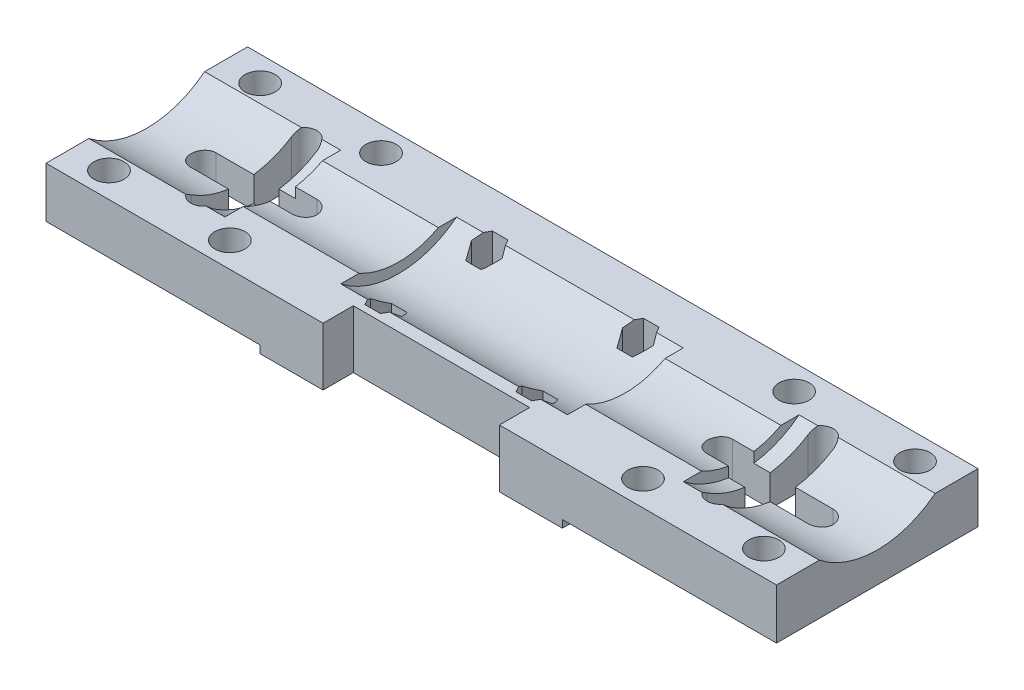
from build123d import *

# Parameters (mm, degrees)
EXTRUDE_1_DEPTH     = 145
SKETCH_2_R          = 3
CUT_EXTRUDE_1_DEPTH = 11
EXTRUDE_2_DEPTH     = 23
SKETCH_4_W          = 60
SKETCH_4_H          = 40
EXTRUDE_3_DEPTH     = 1.5
SKETCH_5_R          = 1.65
CUT_EXTRUDE_2_DEPTH = 12.5
CUT_EXTRUDE_3_DEPTH = 7
SKETCH_8_W          = 35
SKETCH_8_H          = 6
CUT_EXTRUDE_5_DEPTH = 12.5
CUT_EXTRUDE_6_DEPTH = 11


with BuildPart() as part:
    # 草图1 → 凸台-拉伸1 (new body)
    with BuildSketch(Plane(origin=(0, 0, 0), x_dir=(0, 0, -1), z_dir=(1, 0, 0))):
        with BuildLine():
            Line((-20, 10), (-20, 0))
            Line((-20, 0), (20, 0))
            Line((20, 0), (20, 10))
            Line((20, 10), (11.489125293, 10))
            ThreePointArc((11.489125293, 10), (0, 6), (-11.489125293, 10))
            Line((-11.489125293, 10), (-20, 10))
        make_face()
    extrude(amount=EXTRUDE_1_DEPTH)

    # 草图2 → 切除-拉伸1 (cut, through all)
    with BuildSketch(Plane.XZ):
        with Locations((137.5, -15)):
            Circle(SKETCH_2_R)
        with Locations((113.5, -15)):
            Circle(SKETCH_2_R)
        with Locations((113.5, 15)):
            Circle(SKETCH_2_R)
        with Locations((137.5, 15)):
            Circle(SKETCH_2_R)
        with Locations((7.5, 15)):
            Circle(SKETCH_2_R)
        with Locations((31.5, 15)):
            Circle(SKETCH_2_R)
        with Locations((31.5, -15)):
            Circle(SKETCH_2_R)
        with Locations((7.5, -15)):
            Circle(SKETCH_2_R)
    extrude(amount=-CUT_EXTRUDE_1_DEPTH, mode=Mode.SUBTRACT)

    # 草图3 → 凸台-拉伸2 (add)
    with BuildSketch(Plane(origin=(27, 0, 0), x_dir=(0, 0, -1), z_dir=(1, 0, 0))):
        with BuildLine():
            Line((11.489125293, 10), (7.874007874, 10))
            ThreePointArc((7.874007874, 10), (0, 8), (-7.874007874, 10))
            Line((-7.874007874, 10), (-11.489125293, 10))
            ThreePointArc((-11.489125293, 10), (0, 6), (11.489125293, 10))
        make_face()
    extrude_2 = extrude(amount=EXTRUDE_2_DEPTH)

    # 镜向1: 凸台-拉伸2 across plane
    add(extrude_2.mirror(Plane(origin=(72.5, 0, 0), x_dir=(0, 0, 1), z_dir=(1, 0, 0))))

    # 草图4 → 凸台-拉伸3 (add)
    with BuildSketch(Plane.XZ):
        with Locations((72.5, 0)):
            Rectangle(SKETCH_4_W, SKETCH_4_H)
    extrude(amount=EXTRUDE_3_DEPTH)

    # 草图5 → 切除-拉伸2 (cut, through all)
    with BuildSketch(Plane.XZ.offset(1.5)):
        with Locations((57.5, 10)):
            Circle(SKETCH_5_R)
        with Locations((57.5, -10)):
            Circle(SKETCH_5_R)
        with Locations((87.5, -10)):
            Circle(SKETCH_5_R)
        with Locations((87.5, 10)):
            Circle(SKETCH_5_R)
    extrude(amount=-CUT_EXTRUDE_2_DEPTH, mode=Mode.SUBTRACT)

    # 草图6 → 切除-拉伸3 (cut)
    with BuildSketch(Plane(origin=(0, 10, 0), x_dir=(1, 0, 0), z_dir=(0, 1, 0))):
        Polygon((60.559956427, 10), (59.029978213, 12.65), (55.970021787, 12.65), (54.440043573, 10), (55.970021787, 7.35), (59.029978213, 7.35), align=None)
        Polygon((90.559956427, 10), (89.029978213, 12.65), (85.970021787, 12.65), (84.440043573, 10), (85.970021787, 7.35), (89.029978213, 7.35), align=None)
        Polygon((60.559956427, -10), (59.029978213, -7.35), (55.970021787, -7.35), (54.440043573, -10), (55.970021787, -12.65), (59.029978213, -12.65), align=None)
        Polygon((90.559956427, -10), (89.029978213, -7.35), (85.970021787, -7.35), (84.440043573, -10), (85.970021787, -12.65), (89.029978213, -12.65), align=None)
    extrude(amount=-CUT_EXTRUDE_3_DEPTH, mode=Mode.SUBTRACT)

    # 草图8 → 切除-拉伸5 (cut, through all)
    with BuildSketch(Plane(origin=(0, 10, 0), x_dir=(1, 0, 0), z_dir=(0, 1, 0))):
        with Locations((72.5, -17)):
            Rectangle(SKETCH_8_W, SKETCH_8_H)
    extrude(amount=-CUT_EXTRUDE_5_DEPTH, mode=Mode.SUBTRACT)

    # 草图9 → 切除-拉伸6 (cut, through all)
    with BuildSketch(Plane.XZ):
        with BuildLine():
            Line((133.75, -2.5), (126.25, -2.5))
            Line((126.25, -2.5), (126.25, -10))
            ThreePointArc((126.25, -10), (123.75, -12.5), (121.25, -10))
            Line((121.25, -10), (121.25, -2.5))
            Line((121.25, -2.5), (113.75, -2.5))
            ThreePointArc((113.75, -2.5), (111.25, 0), (113.75, 2.5))
            Line((113.75, 2.5), (121.25, 2.5))
            Line((121.25, 2.5), (121.25, 10))
            ThreePointArc((121.25, 10), (123.75, 12.5), (126.25, 10))
            Line((126.25, 10), (126.25, 2.5))
            Line((126.25, 2.5), (133.75, 2.5))
            ThreePointArc((133.75, 2.5), (136.25, 0), (133.75, -2.5))
        make_face()
        with BuildLine():
            Line((23.75, -2.5), (23.75, -10))
            ThreePointArc((23.75, -10), (21.25, -12.5), (18.75, -10))
            Line((18.75, -10), (18.75, -2.5))
            Line((18.75, -2.5), (11.25, -2.5))
            ThreePointArc((11.25, -2.5), (8.75, 0), (11.25, 2.5))
            Line((11.25, 2.5), (18.75, 2.5))
            Line((18.75, 2.5), (18.75, 10))
            ThreePointArc((18.75, 10), (21.25, 12.5), (23.75, 10))
            Line((23.75, 10), (23.75, 2.5))
            Line((23.75, 2.5), (31.25, 2.5))
            ThreePointArc((31.25, 2.5), (33.75, 0), (31.25, -2.5))
            Line((31.25, -2.5), (23.75, -2.5))
        make_face()
    extrude(amount=-CUT_EXTRUDE_6_DEPTH, mode=Mode.SUBTRACT)


solid = part.part
